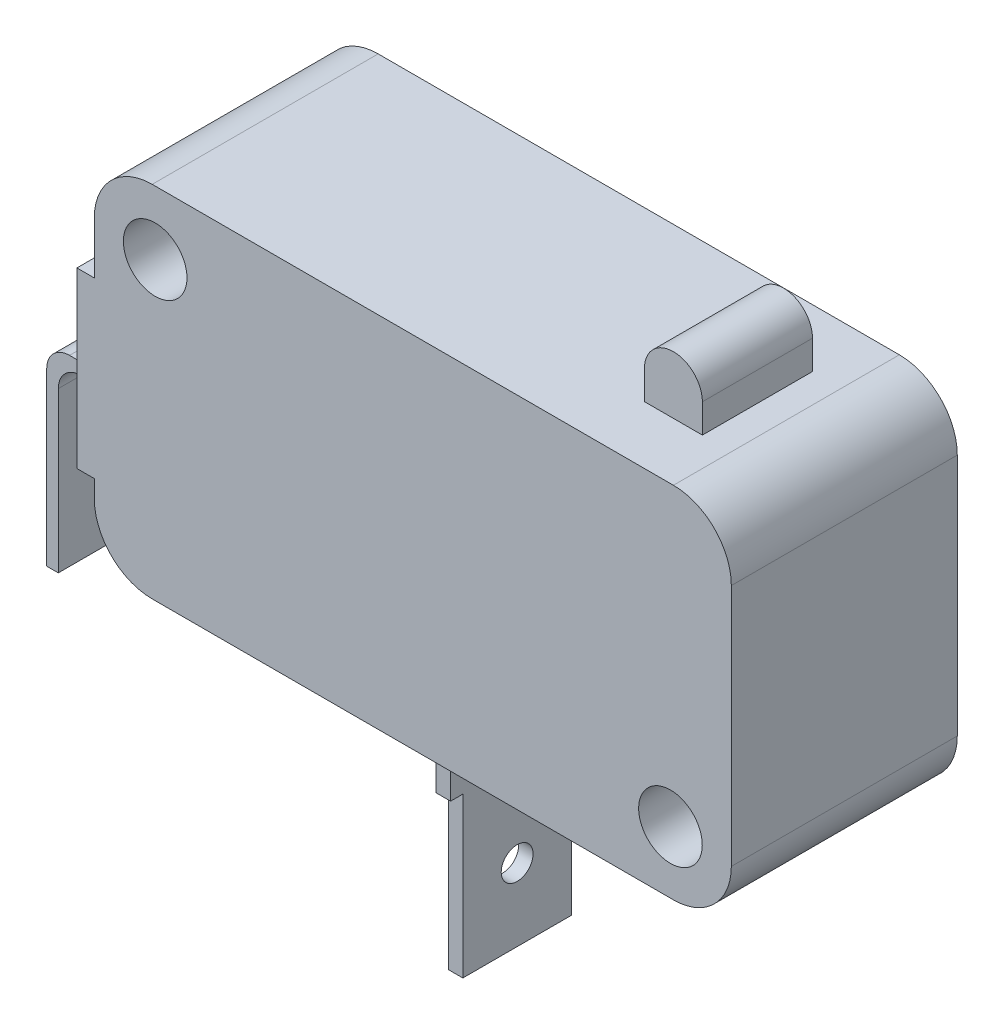
from build123d import *

# Parameters (mm, degrees)
SKETCH1_R      = 1.395
EXTRUDE1_DEPTH = 4.955
EXTRUDE2_DEPTH = 3.105
EXTRUDE3_DEPTH = 2.415
EXTRUDE4_DEPTH = 2.92
EXTRUDE5_REACH = 16.985
SKETCH5_W      = 6.985
SKETCH5_H      = 0.53875
SKETCH5_R      = 0.6985
SKETCH6_R      = 0.635
EXTRUDE7_DEPTH = 1.508
SKETCH_R       = 1.395
EXTRUDE8_DEPTH = 7.92
FILLET1_R      = 1


with BuildPart() as part:
    # Sketch1 → Extrude1 (new body, symmetric)
    with BuildSketch(Plane.XY):
        with Locations((-11.3, 5.08)):
            Circle(SKETCH1_R)
        with BuildLine():
            Line((13.97, -5.334), (13.97, 5.334))
            ThreePointArc((13.97, 5.334), (13.226051224, 7.130051224), (11.43, 7.874))
            Line((11.43, 7.874), (-11.43, 7.874))
            ThreePointArc((-11.43, 7.874), (-13.226051224, 7.130051224), (-13.97, 5.334))
            Line((-13.97, 5.334), (-13.97, 3.048))
            Line((-13.97, 3.048), (-14.732, 3.048))
            Line((-14.732, 3.048), (-14.732, -4.572))
            Line((-14.732, -4.572), (-13.97, -4.572))
            Line((-13.97, -4.572), (-13.97, -5.334))
            ThreePointArc((-13.97, -5.334), (-13.226051224, -7.130051224), (-11.43, -7.874))
            Line((-11.43, -7.874), (11.43, -7.874))
            ThreePointArc((11.43, -7.874), (13.226051224, -7.130051224), (13.97, -5.334))
        make_face()
        with Locations((11.3, -5.16)):
            Circle(SKETCH1_R, mode=Mode.SUBTRACT)
        with Locations((-11.3, 5.08)):
            Circle(SKETCH1_R, mode=Mode.SUBTRACT)
        with Locations((11.3, -5.16)):
            Circle(SKETCH1_R)
    extrude(amount=EXTRUDE1_DEPTH, both=True)

    # Sketch2 → Extrude2 (add, symmetric)
    with BuildSketch(Plane.XY):
        Polygon((-17.907, -2.286), (-17.907, -10.795), (-17.399, -10.795), (-17.399, -2.794), (-14.732, -2.794), (-14.732, -2.286), align=None)
    extrude(amount=EXTRUDE2_DEPTH, both=True)

    # Sketch3 → Extrude3 (add, symmetric)
    with BuildSketch(Plane.XY):
        with BuildLine():
            Line((10.16, 7.874), (10.16, 9.139))
            ThreePointArc((10.16, 9.139), (8.89, 10.409), (7.62, 9.139))
            Line((7.62, 9.139), (7.62, 7.874))
            Line((7.62, 7.874), (10.16, 7.874))
        make_face()
    extrude(amount=EXTRUDE3_DEPTH, both=True)

    # Sketch4 → Extrude4 (add, symmetric)
    with BuildSketch(Plane.XY):
        Polygon((-0.38, -18.034), (-0.38, -10.984), (-1.015, -11.05270614), (-1.015, -18.034), align=None)
        Polygon((-1.015, -11.05270614), (-0.38, -10.984), (-0.38, -7.874), (-1.015, -7.874), (-1.015, -10.414), align=None)
    extrude(amount=EXTRUDE4_DEPTH, both=True)

    # Sketch5 → Extrude5 (cut, up to next)
    with BuildSketch(Plane(origin=(-1.015, -13.250765139, 0), x_dir=(0, -1, 0), z_dir=(-1, 0, 0)), mode=Mode.PRIVATE) as extrude5_sk1:
        with Locations((1.290734861, -2.650625)):
            Rectangle(SKETCH5_W, SKETCH5_H)
    extrude5_tool1 = extrude(extrude5_sk1.sketch, amount=-EXTRUDE5_REACH, mode=Mode.PRIVATE) & part.part
    add(extrude5_tool1.solids().sort_by_distance((-1.015, -14.5415, -2.650625))[0], mode=Mode.SUBTRACT)
    # Sketch5 → Extrude5 (cut, up to next)
    with BuildSketch(Plane(origin=(-1.015, -13.250765139, 0), x_dir=(0, -1, 0), z_dir=(-1, 0, 0)), mode=Mode.PRIVATE) as extrude5_sk2:
        with Locations((1.290734861, 2.650625)):
            Rectangle(SKETCH5_W, SKETCH5_H)
    extrude5_tool2 = extrude(extrude5_sk2.sketch, amount=-EXTRUDE5_REACH, mode=Mode.PRIVATE) & part.part
    add(extrude5_tool2.solids().sort_by_distance((-1.015, -14.5415, 2.650625))[0], mode=Mode.SUBTRACT)
    # Sketch5 → Extrude5 (cut, up to next)
    with BuildSketch(Plane(origin=(-1.015, -13.250765139, 0), x_dir=(0, -1, 0), z_dir=(-1, 0, 0)), mode=Mode.PRIVATE) as extrude5_sk3:
        with Locations((1.608234861, 0)):
            Circle(SKETCH5_R)
    extrude5_tool3 = extrude(extrude5_sk3.sketch, amount=-EXTRUDE5_REACH, mode=Mode.PRIVATE) & part.part
    add(extrude5_tool3.solids().sort_by_distance((-1.015, -14.859, 0))[0], mode=Mode.SUBTRACT)

    # Sketch6 → Extrude7 (cut, through all)
    with BuildSketch(Plane(origin=(-17.399, 14.605, 0), x_dir=(0, 1, 0), z_dir=(1, 0, 0))):
        with Locations((-22.352, 0)):
            Circle(SKETCH6_R)
    extrude(amount=-EXTRUDE7_DEPTH, mode=Mode.SUBTRACT)

    # Sketch → Extrude8 (cut, symmetric)
    with BuildSketch(Plane.XY):
        with Locations((-11.3, 5.08)):
            Circle(SKETCH_R)
        with Locations((11.3, -5.16)):
            Circle(SKETCH_R)
    extrude(amount=EXTRUDE8_DEPTH, both=True, mode=Mode.SUBTRACT)

    # Fillet1
    fillet1_edges = [part.edges().sort_by_distance(p)[0] for p in [
        (-17.907, -2.286, 0),
        (-17.399, -2.794, 0),
    ]]
    fillet(fillet1_edges, radius=FILLET1_R)


solid = part.part
